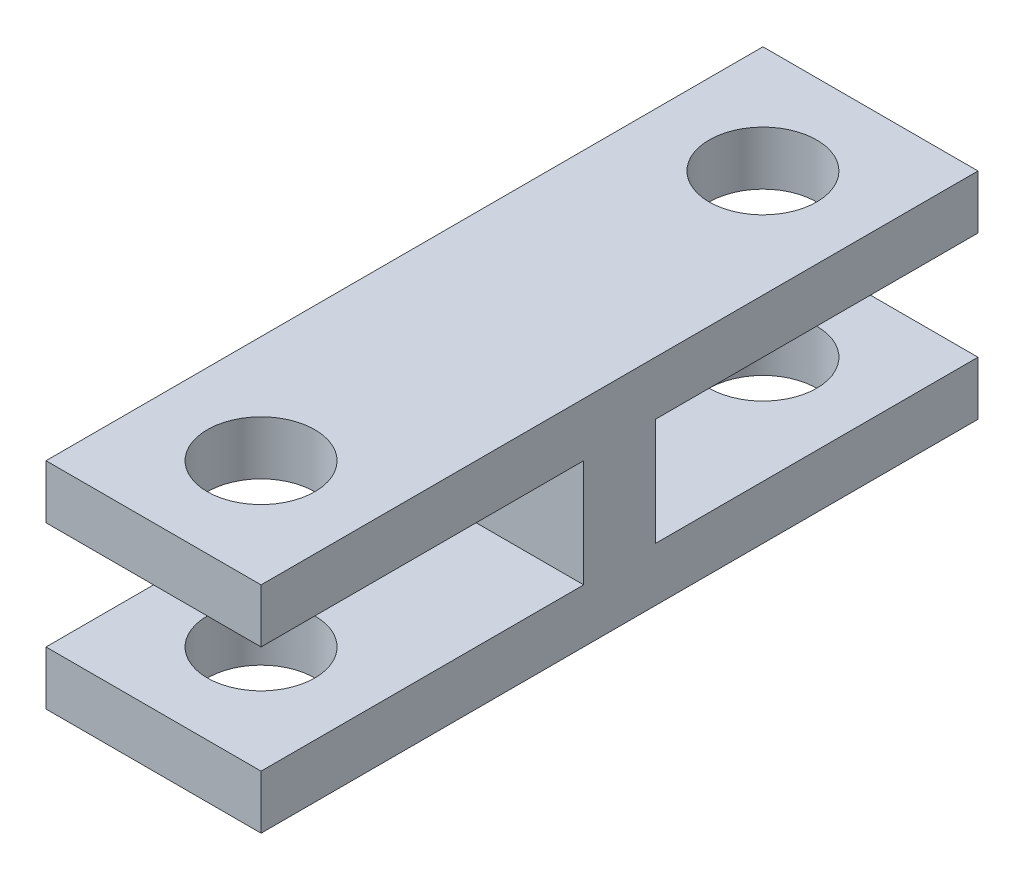
from build123d import *

# Parameters (mm, degrees)
BOSS_EXTRUDE1_DEPTH = 6
SKETCH2_R           = 1.5
CUT_EXTRUDE1_DEPTH  = 7


with BuildPart() as part:
    # Sketch1 → Boss-Extrude1 (new body)
    with BuildSketch(Plane(origin=(0, 0, 0), x_dir=(0, 0, -1), z_dir=(1, 0, 0))):
        Polygon((-4.581861398, -8.60824031), (4.418138602, -8.60824031), (4.418138602, -5.60824031), (-4.581861398, -5.60824031), (-4.581861398, -4.10824031), (15.418138602, -4.10824031), (15.418138602, -5.60824031), (6.418138602, -5.60824031), (6.418138602, -8.60824031), (15.418138602, -8.60824031), (15.418138602, -10.10824031), (-4.581861398, -10.10824031), align=None)
    extrude(amount=BOSS_EXTRUDE1_DEPTH)

    # Sketch2 → Cut-Extrude1 (cut, through all)
    with BuildSketch(Plane(origin=(0, -4.10824031, 0), x_dir=(1, 0, 0), z_dir=(0, 1, 0))):
        with Locations((3, -1.581861398)):
            Circle(SKETCH2_R)
        with Locations((3, 12.418138602)):
            Circle(SKETCH2_R)
    extrude(amount=-CUT_EXTRUDE1_DEPTH, mode=Mode.SUBTRACT)


solid = part.part
